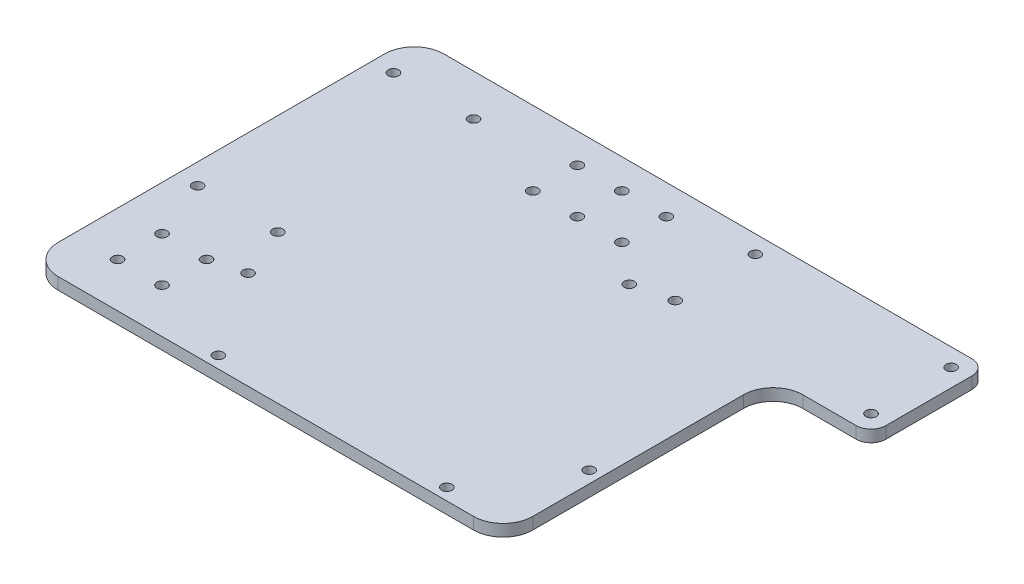
from build123d import *

# Parameters (mm, degrees)
SKETCH_1_W          = 160
SKETCH_1_H          = 130
EXTRUDE_1_DEPTH     = 4
SKETCH_2_R          = 1.75
CUT_EXTRUDE_1_DEPTH = 5
SKETCH_4_R          = 1.75
CUT_EXTRUDE_2_DEPTH = 5
SKETCH_5_R          = 1.75
CUT_EXTRUDE_3_DEPTH = 5
SKETCH_6_R          = 1.75
CUT_EXTRUDE_4_DEPTH = 5
SKETCH_7_W          = 33
SKETCH_7_H          = 39
EXTRUDE_2_DEPTH     = 4
SKETCH_8_R          = 1.75
CUT_EXTRUDE_5_DEPTH = 5
FILLET_1_R          = 10
FILLET_2_R          = 5
SKETCH_9_R          = 1.75
CUT_EXTRUDE_6_DEPTH = 5


with BuildPart() as part:
    # ｽｹｯﾁ1 → ﾎﾞｽ - 押し出し1 (new body)
    with BuildSketch(Plane(origin=(0, 0, 0), x_dir=(1, 0, 0), z_dir=(0, 1, 0))):
        Rectangle(SKETCH_1_W, SKETCH_1_H)
    extrude(amount=EXTRUDE_1_DEPTH)

    # ｽｹｯﾁ2 → ｶｯﾄ - 押し出し1 (cut, through all)
    with BuildSketch(Plane(origin=(0, 4, 0), x_dir=(1, 0, 0), z_dir=(0, 1, 0))):
        with Locations((-73, -15)):
            Circle(SKETCH_2_R)
        with Locations((-73, 51)):
            Circle(SKETCH_2_R)
        with Locations((-46, -15)):
            Circle(SKETCH_2_R)
        with Locations((-46, 51)):
            Circle(SKETCH_2_R)
    extrude(amount=-CUT_EXTRUDE_1_DEPTH, mode=Mode.SUBTRACT)

    # ｽｹｯﾁ4 → ｶｯﾄ - 押し出し2 (cut, through all)
    with BuildSketch(Plane(origin=(0, 4, 0), x_dir=(1, 0, 0), z_dir=(0, 1, 0))):
        with Locations((41, 59)):
            Circle(SKETCH_4_R)
        with Locations((41, 32)):
            Circle(SKETCH_4_R)
    extrude(amount=-CUT_EXTRUDE_2_DEPTH, mode=Mode.SUBTRACT)

    # ｽｹｯﾁ5 → ｶｯﾄ - 押し出し3 (cut, through all)
    with BuildSketch(Plane(origin=(0, 4, 0), x_dir=(1, 0, 0), z_dir=(0, 1, 0))):
        with Locations((57, -61)):
            Circle(SKETCH_5_R)
        with Locations((-20, -61)):
            Circle(SKETCH_5_R)
        with Locations((-39, -32)):
            Circle(SKETCH_5_R)
        with Locations((76, -32)):
            Circle(SKETCH_5_R)
        with Locations((28.5, 29)):
            Circle(SKETCH_5_R)
    extrude(amount=-CUT_EXTRUDE_3_DEPTH, mode=Mode.SUBTRACT)

    # ｽｹｯﾁ6 → ｶｯﾄ - 押し出し4 (cut, through all)
    with BuildSketch(Plane(origin=(0, 4, 0), x_dir=(1, 0, 0), z_dir=(0, 1, 0))):
        with Locations((0, 55)):
            Circle(SKETCH_6_R)
        with Locations((0, 40)):
            Circle(SKETCH_6_R)
        with Locations((15, 55)):
            Circle(SKETCH_6_R)
        with Locations((15, 40)):
            Circle(SKETCH_6_R)
        with Locations((-15, 55)):
            Circle(SKETCH_6_R)
        with Locations((-15, 40)):
            Circle(SKETCH_6_R)
    extrude(amount=-CUT_EXTRUDE_4_DEPTH, mode=Mode.SUBTRACT)

    # ｽｹｯﾁ7 → ﾎﾞｽ - 押し出し2 (add)
    with BuildSketch(Plane(origin=(0, 4, 0), x_dir=(1, 0, 0), z_dir=(0, 1, 0))):
        with Locations((96.5, 45.5)):
            Rectangle(SKETCH_7_W, SKETCH_7_H)
    extrude(amount=-EXTRUDE_2_DEPTH)

    # ｽｹｯﾁ8 → ｶｯﾄ - 押し出し5 (cut, through all)
    with BuildSketch(Plane(origin=(0, 4, 0), x_dir=(1, 0, 0), z_dir=(0, 1, 0))):
        with Locations((107, 59)):
            Circle(SKETCH_8_R)
        with Locations((107, 32)):
            Circle(SKETCH_8_R)
    extrude(amount=-CUT_EXTRUDE_5_DEPTH, mode=Mode.SUBTRACT)

    # ﾌｨﾚｯﾄ1
    fillet_1_edges = [part.edges().sort_by_distance(p)[0] for p in [
        (80, 2, 65),
        (-80, 2, 65),
        (-80, 2, -65),
        (80, 2, -26),
    ]]
    fillet(fillet_1_edges, radius=FILLET_1_R)

    # ﾌｨﾚｯﾄ2
    fillet_2_edges = [part.edges().sort_by_distance(p)[0] for p in [
        (113, 2, -65),
        (113, 2, -26),
    ]]
    fillet(fillet_2_edges, radius=FILLET_2_R)

    # ｽｹｯﾁ9 → ｶｯﾄ - 押し出し6 (cut, through all)
    with BuildSketch(Plane(origin=(0, 4, 0), x_dir=(1, 0, 0), z_dir=(0, 1, 0))):
        with Locations((-65, -50)):
            Circle(SKETCH_9_R)
        with Locations((-50, -50)):
            Circle(SKETCH_9_R)
        with Locations((-65, -35)):
            Circle(SKETCH_9_R)
        with Locations((-50, -35)):
            Circle(SKETCH_9_R)
    extrude(amount=-CUT_EXTRUDE_6_DEPTH, mode=Mode.SUBTRACT)


solid = part.part
